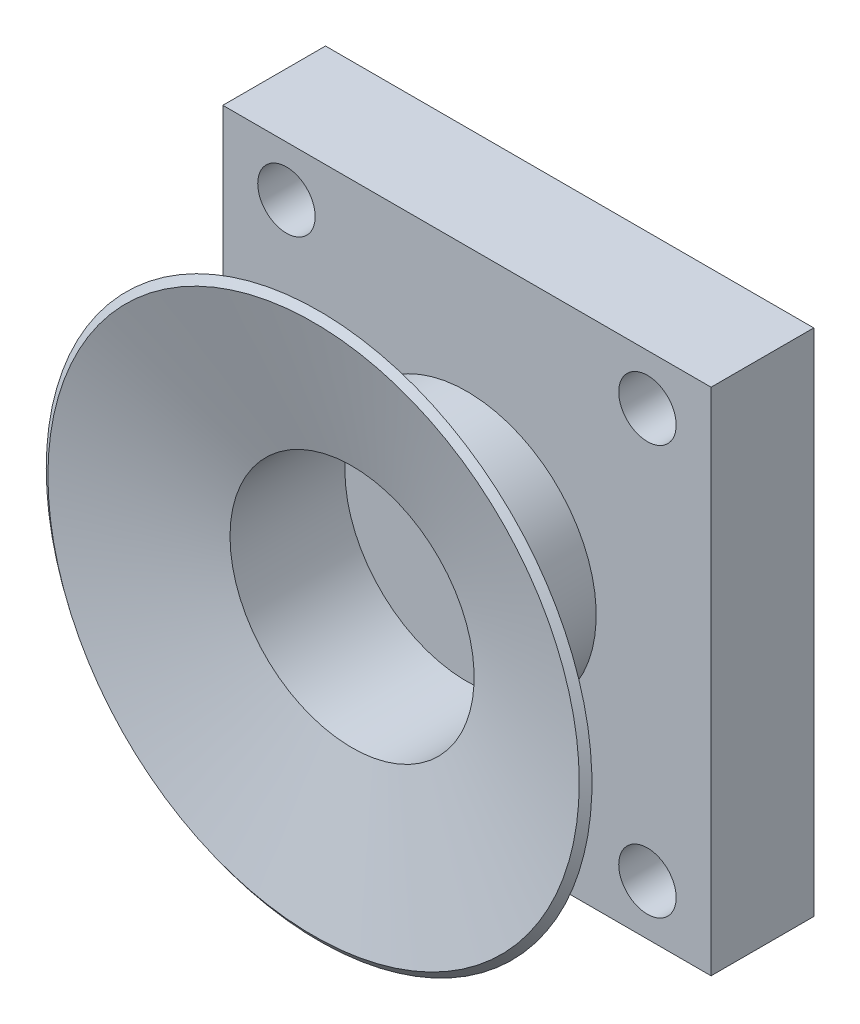
from build123d import *

# Parameters (mm, degrees)
SKETCH1_W           = 34
SKETCH1_H           = 35.5
SKETCH1_R           = 2
BOSS_EXTRUDE1_DEPTH = 7.15


with BuildPart() as part:
    # Sketch1 → Boss-Extrude1 (new body)
    with BuildSketch(Plane.XY):
        with Locations((17, 17.75)):
            Rectangle(SKETCH1_W, SKETCH1_H)
        with Locations((4.431526268, 3.5)):
            Circle(SKETCH1_R, mode=Mode.SUBTRACT)
        with Locations((29.568473732, 3.5)):
            Circle(SKETCH1_R, mode=Mode.SUBTRACT)
        with Locations((29.568473732, 32)):
            Circle(SKETCH1_R, mode=Mode.SUBTRACT)
        with Locations((4.431526268, 32)):
            Circle(SKETCH1_R, mode=Mode.SUBTRACT)
    extrude(amount=BOSS_EXTRUDE1_DEPTH)

    # Sketch4 → Revolve2 (revolve)
    with BuildSketch(Plane(origin=(17, 0, 0), x_dir=(0, 0, -1), z_dir=(1, 0, 0))):
        Polygon((-7.15, 26.25), (-15.15, 26.25), (-17.829491924, 36.25), (-17.44582843, 36.75), (-14.766336506, 26.75), (-7.15, 26.75), align=None)
    revolve(axis=Axis((17, 17.75, 7.15), (0, 0, 1)))


solid = part.part
